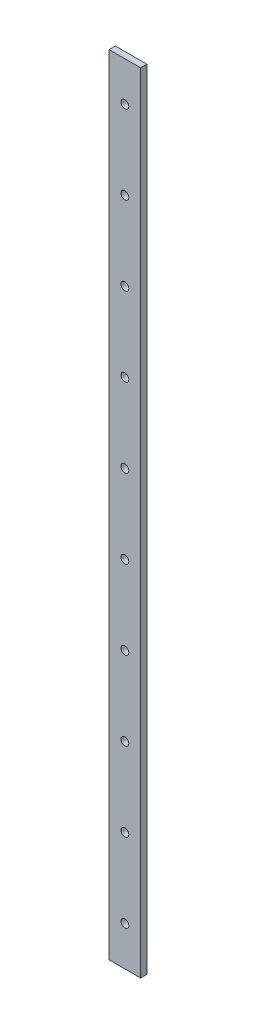
from build123d import *

# Parameters (mm, degrees)
SKETCH_1_W          = 20
SKETCH_1_H          = 4
EXTRUDE_1_DEPTH     = 500
SKETCH_2_R          = 2.5
CUT_EXTRUDE_1_DEPTH = 5


with BuildPart() as part:
    # Эскиз1 → Бобышка-Вытянуть1 (new body)
    with BuildSketch(Plane(origin=(0, 0, 0), x_dir=(1, 0, 0), z_dir=(0, 1, 0))):
        Rectangle(SKETCH_1_W, SKETCH_1_H)
    extrude(amount=EXTRUDE_1_DEPTH)

    # Эскиз2 → Вырез-Вытянуть1 (cut, through all)
    with BuildSketch(Plane.XY.offset(2)):
        with Locations((0, 25)):
            Circle(SKETCH_2_R)
        with Locations((0, 75)):
            Circle(SKETCH_2_R)
        with Locations((0, 125)):
            Circle(SKETCH_2_R)
        with Locations((0, 175)):
            Circle(SKETCH_2_R)
        with Locations((0, 225)):
            Circle(SKETCH_2_R)
        with Locations((0, 275)):
            Circle(SKETCH_2_R)
        with Locations((0, 325)):
            Circle(SKETCH_2_R)
        with Locations((0, 375)):
            Circle(SKETCH_2_R)
        with Locations((0, 425)):
            Circle(SKETCH_2_R)
        with Locations((0, 475)):
            Circle(SKETCH_2_R)
    extrude(amount=-CUT_EXTRUDE_1_DEPTH, mode=Mode.SUBTRACT)


solid = part.part
